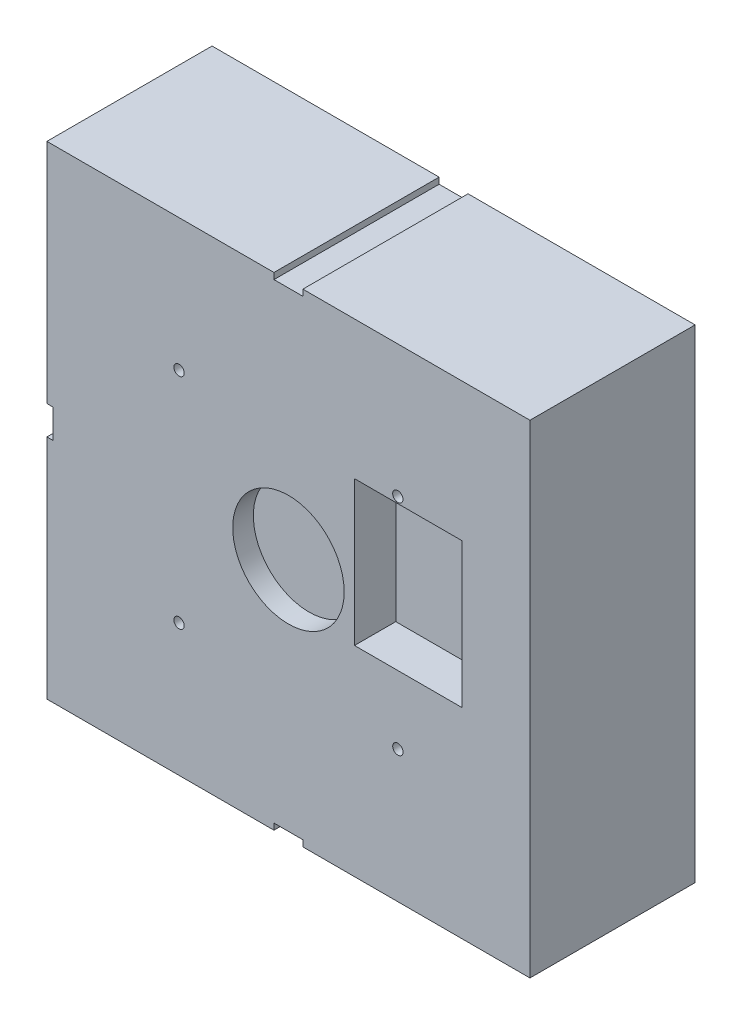
from build123d import *

# Parameters (mm, degrees)
SKETCH1_W            = 117
SKETCH1_H            = 117
BODY_DEPTH           = 40
SKETCH4_W            = 7
SKETCH4_H            = 3
SKETCH4_W_2          = 3
SKETCH4_H_2          = 7
RAILS_HOUSINGS_DEPTH = 41
DRILL_START          = -40
SKETCH6_R            = 1.25
DRILL_HOLES_DEPTH    = 10
PCB_START            = -40
SKETCH7_W            = 26
SKETCH7_H            = 35
PCB_GAP_DEPTH        = 10
MOTOR_START          = -40
SKETCH8_R            = 13.5
MOTOR_GAP_DEPTH      = 5
SKETCH13_W           = 40
SKETCH13_H           = 7
BOSS_EXTRUDE4_DEPTH  = 1.5


with BuildPart() as part:
    # Sketch1 → body (new body)
    with BuildSketch(Plane.XY):
        Rectangle(SKETCH1_W, SKETCH1_H)
    extrude(amount=BODY_DEPTH)

    # Sketch4 → rails housings (cut, through all)
    with BuildSketch(Plane(origin=(0, 0, 0), x_dir=(-1, 0, 0), z_dir=(0, 0, -1))):
        with Locations((0, 58.5)):
            Rectangle(SKETCH4_W, SKETCH4_H)
        with Locations((58.5, 0)):
            Rectangle(SKETCH4_W_2, SKETCH4_H_2)
        with Locations((0, -58.5)):
            Rectangle(SKETCH4_W, SKETCH4_H)
        with Locations((-58.5, 0)):
            Rectangle(SKETCH4_W_2, SKETCH4_H_2)
    extrude(amount=-RAILS_HOUSINGS_DEPTH, mode=Mode.SUBTRACT)

    # Sketch6 → drill holes (cut)
    with BuildSketch(Plane(origin=(0, 0, 0), x_dir=(-1, 0, 0), z_dir=(0, 0, -1)).offset(DRILL_START)):
        with Locations((-26.5, 26.5)):
            Circle(SKETCH6_R)
        with Locations((26.5, 26.5)):
            Circle(SKETCH6_R)
        with Locations((26.5, -26.5)):
            Circle(SKETCH6_R)
        with Locations((-26.5, -26.5)):
            Circle(SKETCH6_R)
    extrude(amount=DRILL_HOLES_DEPTH, mode=Mode.SUBTRACT)

    # Sketch7 → PCB gap (cut)
    with BuildSketch(Plane(origin=(0, 0, 0), x_dir=(-1, 0, 0), z_dir=(0, 0, -1)).offset(PCB_START)):
        with Locations((-29, 7.5)):
            Rectangle(SKETCH7_W, SKETCH7_H)
    extrude(amount=PCB_GAP_DEPTH, mode=Mode.SUBTRACT)

    # Sketch8 → motor gap (cut)
    with BuildSketch(Plane(origin=(0, 0, 0), x_dir=(-1, 0, 0), z_dir=(0, 0, -1)).offset(MOTOR_START)):
        Circle(SKETCH8_R)
    extrude(amount=MOTOR_GAP_DEPTH, mode=Mode.SUBTRACT)

    # Sketch13 → Boss-Extrude4 (add)
    with BuildSketch(Plane(origin=(57, 0, 0), x_dir=(0, 0, -1), z_dir=(1, 0, 0))):
        with Locations((-20, 0)):
            Rectangle(SKETCH13_W, SKETCH13_H)
    extrude(amount=BOSS_EXTRUDE4_DEPTH)


solid = part.part
